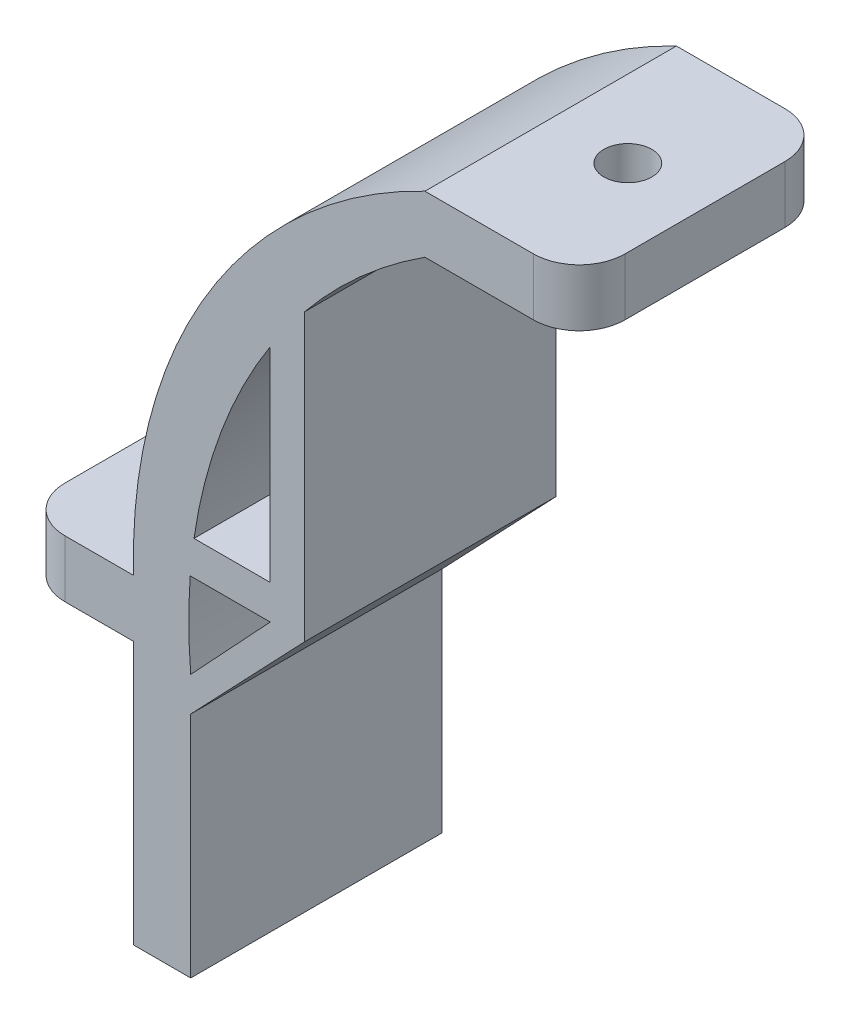
from build123d import *

# Parameters (mm, degrees)
SKETCH3_W                = 13.5
SKETCH3_H                = 5
SKETCH3_W_2              = 10
SKETCH3_W_3              = 5
SKETCH3_H_2              = 23
BOSS_EXTRUDE1_DEPTH      = 45
FILLET1_R                = 2
SKETCH5_R                = 2.1
CUT_EXTRUDE2_DEPTH       = 45
SKETCH6_R                = 2.1
CUT_EXTRUDE3_DEPTH       = 45
SKETCH7_W                = 8.210459319
SKETCH7_H                = 32.58724939
BOSS_EXTRUDE2_DEPTH      = 5
SKETCH8_R                = 2.1
CUT_EXTRUDE5_DEPTH       = 45
BOSS_EXTRUDE3_DEPTH      = 45
SKETCH10_W               = 60.355694637
SKETCH10_H               = 75.381613981
CUT_EXTRUDE7_DEPTH       = 9
SKETCH13_W               = 6.095088126
SKETCH13_H               = 29.055723933
BOSS_EXTRUDE6_DEPTH      = 5
SKETCH14_W               = 6.424633762
SKETCH14_H               = 30.784703445
BOSS_EXTRUDE7_DEPTH      = 5
FILLET3_R                = 2
SKETCH15_R               = 2.1
CUT_EXTRUDE8_DEPTH       = 9
SKETCH16_R               = 2.1
CUT_EXTRUDE9_DEPTH       = 9
SKETCH17_R               = 2.1
SKETCH17_W               = 51.061541061
SKETCH17_H               = 6.00536962
SKETCH17_W_2             = 58.971241115
SKETCH17_H_2             = 35.120826058
CUT_EXTRUDE10_DEPTH      = 42.850344031
CUT_EXTRUDE10_DEPTH_BACK = 29
BOSS_EXTRUDE8_DEPTH      = 5
BOSS_EXTRUDE9_DEPTH      = 5
FILLET5_R                = 4


with BuildPart() as part:
    # Sketch3 → Boss-Extrude1 (new body)
    with BuildSketch(Plane.XY):
        with BuildLine():
            ThreePointArc((-5.06519953, 257.264696919), (-21.146881422, 239.197551787), (-25.551614771, 215.414352888))
            Line((-25.551614771, 215.414352888), (-30.551614771, 215.414352888))
            Line((-30.551614771, 215.414352888), (-30.551614771, 220.414352888))
            ThreePointArc((-30.551614771, 220.414352888), (-24.004098535, 245.112635185), (-5.06519953, 262.264696919))
            Line((-5.06519953, 262.264696919), (-5.06519953, 257.264696919))
        make_face()
        with Locations((1.68480047, 259.764696919)):
            Rectangle(SKETCH3_W, SKETCH3_H)
        with Locations((-35.551614771, 217.914352888)):
            Rectangle(SKETCH3_W_2, SKETCH3_H)
        with Locations((-28.051614771, 203.914352888)):
            Rectangle(SKETCH3_W_3, SKETCH3_H_2)
    extrude(amount=BOSS_EXTRUDE1_DEPTH)

    # Fillet1
    fillet1_edges = [part.edges().sort_by_distance(p)[0] for p in [
        (-40.551614771, 217.914352888, 0),
        (8.43480047, 259.764696919, 45),
        (8.43480047, 259.764696919, 0),
        (-40.551614771, 217.914352888, 45),
    ]]
    fillet(fillet1_edges, radius=FILLET1_R)

    # Sketch5 → Cut-Extrude2 (cut)
    with BuildSketch(Plane(origin=(0, 262.264696919, 0), x_dir=(1, 0, 0), z_dir=(0, 1, 0))):
        with Locations((0.24480047, -40)):
            Circle(SKETCH5_R)
        with Locations((0.24480047, -14.8)):
            Circle(SKETCH5_R)
    extrude(amount=-CUT_EXTRUDE2_DEPTH, mode=Mode.SUBTRACT)

    # Sketch6 → Cut-Extrude3 (cut)
    with BuildSketch(Plane(origin=(0, 220.414352888, 0), x_dir=(1, 0, 0), z_dir=(0, 1, 0))):
        with Locations((-35.551614771, -10)):
            Circle(SKETCH6_R)
        with Locations((-35.551614771, -35)):
            Circle(SKETCH6_R)
    extrude(amount=-CUT_EXTRUDE3_DEPTH, mode=Mode.SUBTRACT)

    # Sketch7 → Boss-Extrude2 (add)
    with BuildSketch(Plane(origin=(0, 262.264696919, 0), x_dir=(1, 0, 0), z_dir=(0, 1, 0))):
        with Locations((1.09445166, -26.923464517)):
            Rectangle(SKETCH7_W, SKETCH7_H)
    extrude(amount=-BOSS_EXTRUDE2_DEPTH)

    # Sketch8 → Cut-Extrude5 (cut)
    with BuildSketch(Plane(origin=(0, 262.264696919, 0), x_dir=(1, 0, 0), z_dir=(0, 1, 0))):
        with Locations((0.24480047, -5)):
            Circle(SKETCH8_R)
        with Locations((0.24480047, -30.2)):
            Circle(SKETCH8_R)
    extrude(amount=-CUT_EXTRUDE5_DEPTH, mode=Mode.SUBTRACT)

    # Sketch9 → Boss-Extrude3 (add, through all)
    with BuildSketch(Plane.XY.offset(45)):
        with BuildLine():
            ThreePointArc((-25.265361734, 225.859750777), (-25.456525287, 224.362535182), (-25.597369426, 222.859750777))
            Line((-25.597369426, 222.859750777), (-18.597369426, 222.859750777))
            Line((-18.597369426, 222.859750777), (-15.597369426, 222.859750777))
            Line((-15.597369426, 222.859750777), (-15.597369426, 247.859750777))
            ThreePointArc((-15.597369426, 247.859750777), (-17.156118075, 245.834377519), (-18.597369426, 243.72377838))
            Line((-18.597369426, 243.72377838), (-18.597369426, 225.859750777))
            Line((-18.597369426, 225.859750777), (-25.265361734, 225.859750777))
        make_face()
        Polygon((-15.597369426, 222.859750777), (-18.597369426, 222.859750777), (-25.551614771, 215.414352888), (-25.551614771, 212.414352888), align=None)
    extrude(amount=-BOSS_EXTRUDE3_DEPTH)

    # Sketch10 → Cut-Extrude7 (cut)
    with BuildSketch(Plane.XY.offset(45)):
        with Locations((-21.743046849, 224.573889929)):
            Rectangle(SKETCH10_W, SKETCH10_H)
    extrude(amount=-CUT_EXTRUDE7_DEPTH, mode=Mode.SUBTRACT)

    # Sketch13 → Boss-Extrude6 (add)
    with BuildSketch(Plane(origin=(0, 220.414352888, 0), x_dir=(1, 0, 0), z_dir=(0, 1, 0))):
        with Locations((-35.175849568, -21.472138034)):
            Rectangle(SKETCH13_W, SKETCH13_H)
    extrude(amount=-BOSS_EXTRUDE6_DEPTH)

    # Sketch14 → Boss-Extrude7 (add)
    with BuildSketch(Plane(origin=(0, 262.264696919, 0), x_dir=(1, 0, 0), z_dir=(0, 1, 0))):
        with Locations((0.1637931, -17.411075239)):
            Rectangle(SKETCH14_W, SKETCH14_H)
    extrude(amount=-BOSS_EXTRUDE7_DEPTH)

    # Fillet3
    fillet3_edges = [part.edges().sort_by_distance(p)[0] for p in [
        (-40.551614771, 217.914352888, 36),
        (8.43480047, 259.764696919, 36),
    ]]
    fillet(fillet3_edges, radius=FILLET3_R)

    # Sketch15 → Cut-Extrude8 (cut)
    with BuildSketch(Plane(origin=(0, 220.414352888, 0), x_dir=(1, 0, 0), z_dir=(0, 1, 0))):
        with Locations((-35.551614771, -8)):
            Circle(SKETCH15_R)
        with Locations((-35.551614771, -28)):
            Circle(SKETCH15_R)
    extrude(amount=-CUT_EXTRUDE8_DEPTH, mode=Mode.SUBTRACT)

    # Sketch16 → Cut-Extrude9 (cut)
    with BuildSketch(Plane(origin=(0, 262.264696919, 0), x_dir=(1, 0, 0), z_dir=(0, 1, 0))):
        with Locations((1.68480047, -8)):
            Circle(SKETCH16_R)
        with Locations((1.68480047, -28)):
            Circle(SKETCH16_R)
    extrude(amount=-CUT_EXTRUDE9_DEPTH, mode=Mode.SUBTRACT)

    # Sketch17 → Cut-Extrude10 (cut, two sides)
    with BuildSketch(Plane(origin=(0, 220.414352888, 0), x_dir=(1, 0, 0), z_dir=(0, 1, 0))) as cut_extrude10_sk:
        with Locations((-35.551614771, -8)):
            Circle(SKETCH17_R)
        with Locations((-15.020844241, 1.00268481)):
            Rectangle(SKETCH17_W, SKETCH17_H)
        with Locations((-11.065994214, -31.560413029)):
            Rectangle(SKETCH17_W_2, SKETCH17_H_2)
    extrude(amount=CUT_EXTRUDE10_DEPTH, mode=Mode.SUBTRACT)
    extrude(cut_extrude10_sk.sketch, amount=-CUT_EXTRUDE10_DEPTH_BACK, mode=Mode.SUBTRACT)

    # Sketch18 → Boss-Extrude8 (add)
    with BuildSketch(Plane.XY.offset(14)):
        with BuildLine():
            ThreePointArc((-15.597369426, 247.859750777), (-10.702470586, 252.977898228), (-5.06519953, 257.264696919))
            Line((-5.06519953, 257.264696919), (8.43480047, 257.264696919))
            Line((8.43480047, 257.264696919), (8.43480047, 262.264696919))
            Line((8.43480047, 262.264696919), (-5.06519953, 262.264696919))
            ThreePointArc((-5.06519953, 262.264696919), (-24.004098535, 245.112635185), (-30.551614771, 220.414352888))
            Line((-30.551614771, 220.414352888), (-40.551614771, 220.414352888))
            Line((-40.551614771, 220.414352888), (-40.551614771, 215.414352888))
            Line((-40.551614771, 215.414352888), (-30.551614771, 215.414352888))
            Line((-30.551614771, 215.414352888), (-30.551614771, 192.414352888))
            Line((-30.551614771, 192.414352888), (-25.551614771, 192.414352888))
            Line((-25.551614771, 192.414352888), (-25.551614771, 212.414352888))
            Line((-25.551614771, 212.414352888), (-15.597369426, 222.859750777))
            Line((-15.597369426, 222.859750777), (-15.597369426, 247.859750777))
        make_face()
        with BuildLine():
            ThreePointArc((-25.551614771, 215.414352888), (-25.728742574, 219.136103908), (-25.597369426, 222.859750777))
            Line((-25.597369426, 222.859750777), (-18.597369426, 222.859750777))
            Line((-18.597369426, 222.859750777), (-25.551614771, 215.414352888))
        make_face(mode=Mode.SUBTRACT)
        with BuildLine():
            ThreePointArc((-25.265361734, 225.859750777), (-22.888422833, 235.14899927), (-18.597369426, 243.72377838))
            Line((-18.597369426, 243.72377838), (-18.597369426, 225.859750777))
            Line((-18.597369426, 225.859750777), (-25.265361734, 225.859750777))
        make_face(mode=Mode.SUBTRACT)
    extrude(amount=BOSS_EXTRUDE8_DEPTH)

    # Sketch19 → Boss-Extrude9 (add)
    with BuildSketch(Plane(origin=(0, 0, 2), x_dir=(-1, 0, 0), z_dir=(0, 0, -1))):
        with BuildLine():
            Line((-8.43480047, 257.264696919), (5.06519953, 257.264696919))
            ThreePointArc((5.06519953, 257.264696919), (10.702470586, 252.977898228), (15.597369426, 247.859750777))
            Line((15.597369426, 247.859750777), (15.597369426, 222.859750777))
            Line((15.597369426, 222.859750777), (25.551614771, 212.414352888))
            Line((25.551614771, 212.414352888), (25.551614771, 192.414352888))
            Line((25.551614771, 192.414352888), (30.551614771, 192.414352888))
            Line((30.551614771, 192.414352888), (30.551614771, 215.414352888))
            Line((30.551614771, 215.414352888), (40.551614771, 215.414352888))
            Line((40.551614771, 215.414352888), (40.551614771, 220.414352888))
            Line((40.551614771, 220.414352888), (30.551614771, 220.414352888))
            ThreePointArc((30.551614771, 220.414352888), (24.004098535, 245.112635185), (5.06519953, 262.264696919))
            Line((5.06519953, 262.264696919), (-8.43480047, 262.264696919))
            Line((-8.43480047, 262.264696919), (-8.43480047, 257.264696919))
        make_face()
        with BuildLine():
            Line((18.597369426, 222.859750777), (25.597369426, 222.859750777))
            ThreePointArc((25.597369426, 222.859750777), (25.728742574, 219.136103908), (25.551614771, 215.414352888))
            Line((25.551614771, 215.414352888), (18.597369426, 222.859750777))
        make_face(mode=Mode.SUBTRACT)
        with BuildLine():
            Line((18.597369426, 225.859750777), (18.597369426, 243.72377838))
            ThreePointArc((18.597369426, 243.72377838), (22.888422833, 235.14899927), (25.265361734, 225.859750777))
            Line((25.265361734, 225.859750777), (18.597369426, 225.859750777))
        make_face(mode=Mode.SUBTRACT)
    extrude(amount=BOSS_EXTRUDE9_DEPTH)

    # Fillet5
    fillet5_edges = [part.edges().sort_by_distance(p)[0] for p in [
        (-40.551614771, 217.914352888, 19),
        (8.43480047, 259.764696919, 19),
        (-40.551614771, 217.914352888, -3),
        (8.43480047, 259.764696919, -3),
    ]]
    fillet(fillet5_edges, radius=FILLET5_R)


solid = part.part
